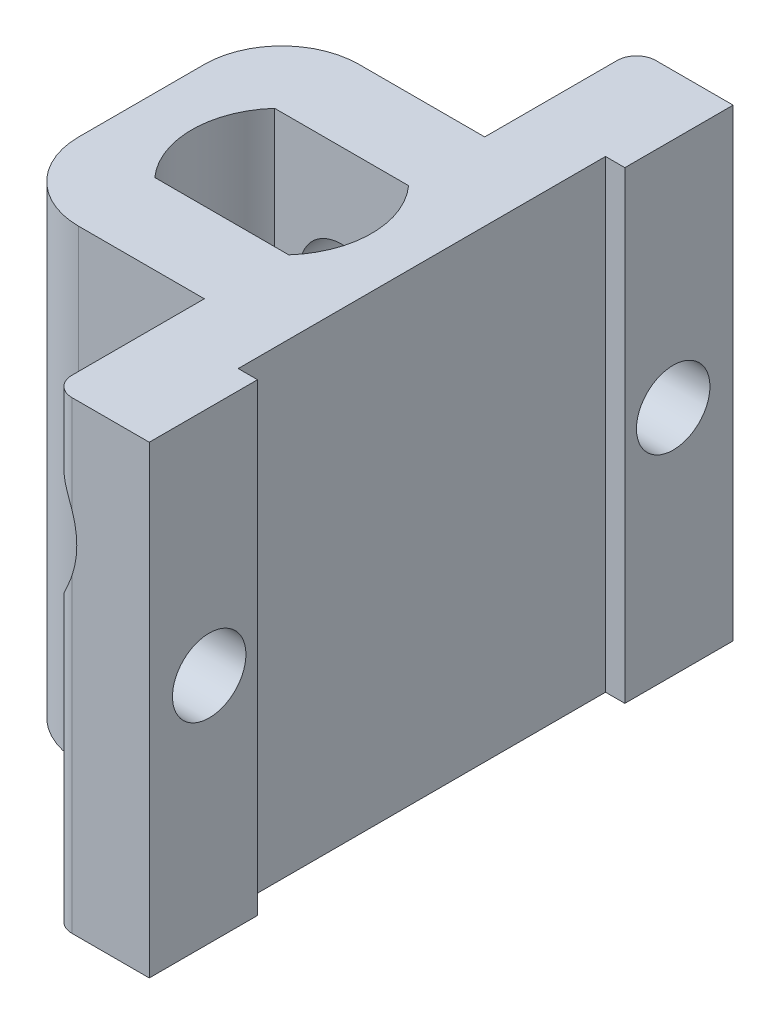
from build123d import *

# Parameters (mm, degrees)
SKETCH_1_W               = 14.5
SKETCH_1_H               = 14.5
EXTRUDE_1_DEPTH          = 10.5
SKETCH_4_R               = 2.15
CUT_EXTRUDE_2_DEPTH      = 8.25
CUT_EXTRUDE_2_DEPTH_BACK = 8.25
SKETCH_6_W               = 14.5
SKETCH_6_H               = 14.5
EXTRUDE_2_DEPTH          = 13.5
SKETCH_9_W               = 4
SKETCH_9_H               = 24
EXTRUDE_3_DEPTH          = 12
SKETCH_10_W              = 5.6
SKETCH_10_H              = 24
EXTRUDE_4_DEPTH          = 1
SKETCH_11_R              = 4.5
CUT_EXTRUDE_3_DEPTH      = 7.85
SKETCH_12_R              = 1.9
CUT_EXTRUDE_4_DEPTH      = 1
CUT_EXTRUDE_4_DEPTH_BACK = 16.5
FILLET_1_R               = 4
FILLET_3_R               = 1


with BuildPart() as part:
    # 草图1 → 凸台-拉伸1 (new body)
    with BuildSketch(Plane(origin=(0, 0, 0), x_dir=(1, 0, 0), z_dir=(0, 1, 0))):
        Rectangle(SKETCH_1_W, SKETCH_1_H)
        with BuildLine():
            Line((3.465905365, -3.1), (-3.465905365, -3.1))
            ThreePointArc((-3.465905365, -3.1), (-4.65, 0), (-3.465905365, 3.1))
            Line((-3.465905365, 3.1), (3.465905365, 3.1))
            ThreePointArc((3.465905365, 3.1), (4.65, 0), (3.465905365, -3.1))
        make_face(mode=Mode.SUBTRACT)
    extrude(amount=EXTRUDE_1_DEPTH)

    # 草图4 → 切除-拉伸2 (cut, two sides)
    with BuildSketch(Plane.XY) as cut_extrude_2_sk:
        with Locations((0, 4)):
            Circle(SKETCH_4_R)
    extrude(amount=CUT_EXTRUDE_2_DEPTH, mode=Mode.SUBTRACT)
    extrude(cut_extrude_2_sk.sketch, amount=-CUT_EXTRUDE_2_DEPTH_BACK, mode=Mode.SUBTRACT)

    # 草图6 → 凸台-拉伸2 (add)
    with BuildSketch(Plane.XZ):
        Rectangle(SKETCH_6_W, SKETCH_6_H)
        with BuildLine():
            Line((-3.465905365, -3.1), (3.465905365, -3.1))
            ThreePointArc((3.465905365, -3.1), (4.65, 0), (3.465905365, 3.1))
            Line((3.465905365, 3.1), (-3.465905365, 3.1))
            ThreePointArc((-3.465905365, 3.1), (-4.65, 0), (-3.465905365, -3.1))
        make_face(mode=Mode.SUBTRACT)
    extrude(amount=EXTRUDE_2_DEPTH)

    # 草图9 → 凸台-拉伸3 (add)
    with BuildSketch(Plane.XY.offset(-3.1)):
        with Locations((5.25, -1.5)):
            Rectangle(SKETCH_9_W, SKETCH_9_H)
    extrude_3 = extrude(amount=-EXTRUDE_3_DEPTH)

    # 镜向1: 凸台-拉伸3 across plane
    add(extrude_3.mirror(Plane.XY))

    # 草图10 → 凸台-拉伸4 (add)
    with BuildSketch(Plane(origin=(7.25, 0, 0), x_dir=(0, 0, -1), z_dir=(1, 0, 0))):
        with Locations((-12.3, -1.5)):
            Rectangle(SKETCH_10_W, SKETCH_10_H)
        with Locations((12.3, -1.5)):
            Rectangle(SKETCH_10_W, SKETCH_10_H)
    extrude(amount=EXTRUDE_4_DEPTH)

    # 草图11 → 切除-拉伸3 (cut)
    with BuildSketch(Plane.XY.offset(15.1)):
        with Locations((0, 4)):
            Circle(SKETCH_11_R)
    cut_extrude_3 = extrude(amount=-CUT_EXTRUDE_3_DEPTH, mode=Mode.SUBTRACT)

    # 镜向2: 切除-拉伸3 across plane
    add(cut_extrude_3.mirror(Plane.XY), mode=Mode.SUBTRACT)

    # 草图12 → 切除-拉伸4 (cut, two sides)
    with BuildSketch(Plane(origin=(8.25, 0, 0), x_dir=(0, 0, -1), z_dir=(1, 0, 0))) as cut_extrude_4_sk:
        with Locations((12, -1.5)):
            Circle(SKETCH_12_R)
        with Locations((-12, -1.5)):
            Circle(SKETCH_12_R)
    extrude(amount=CUT_EXTRUDE_4_DEPTH, mode=Mode.SUBTRACT)
    extrude(cut_extrude_4_sk.sketch, amount=-CUT_EXTRUDE_4_DEPTH_BACK, mode=Mode.SUBTRACT)

    # 圆角1
    fillet_1_edges = [part.edges().sort_by_distance(p)[0] for p in [
        (-7.25, -1.5, 7.25),
        (-7.25, -1.5, -7.25),
    ]]
    fillet(fillet_1_edges, radius=FILLET_1_R)

    # 圆角3
    fillet_3_edges = [part.edges().sort_by_distance(p)[0] for p in [
        (3.25, -6.30623745, 15.1),
        (3.25, -6.30623745, -15.1),
        (3.25, 8.80623745, -15.1),
        (3.25, 8.80623745, 15.1),
    ]]
    fillet(fillet_3_edges, radius=FILLET_3_R)


solid = part.part
